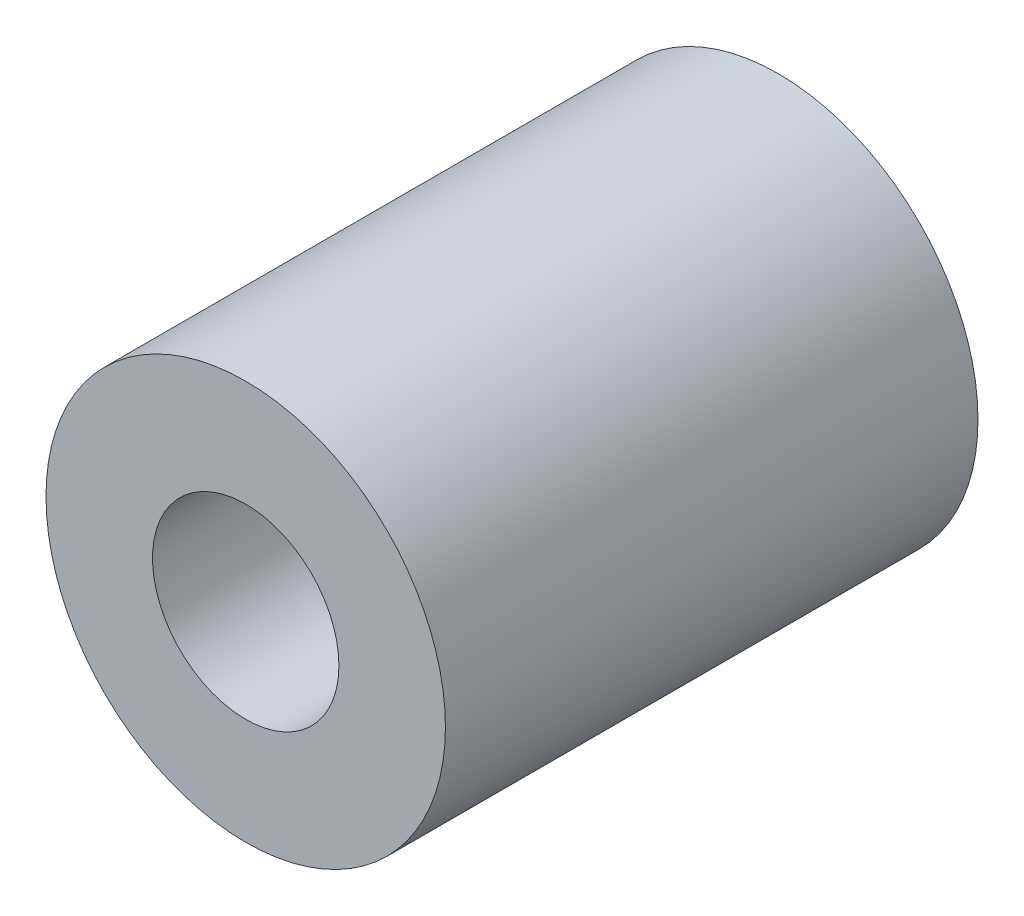
from build123d import *

# Parameters (mm, degrees)
ESQUISSE1_R        = 3.75
ESQUISSE1_R_2      = 1.75
BOSS_EXTRU_1_DEPTH = 10


with BuildPart() as part:
    # Esquisse1 → Boss.-Extru.1 (new body)
    with BuildSketch(Plane.XY):
        Circle(ESQUISSE1_R)
        Circle(ESQUISSE1_R_2, mode=Mode.SUBTRACT)
    extrude(amount=BOSS_EXTRU_1_DEPTH)


solid = part.part
